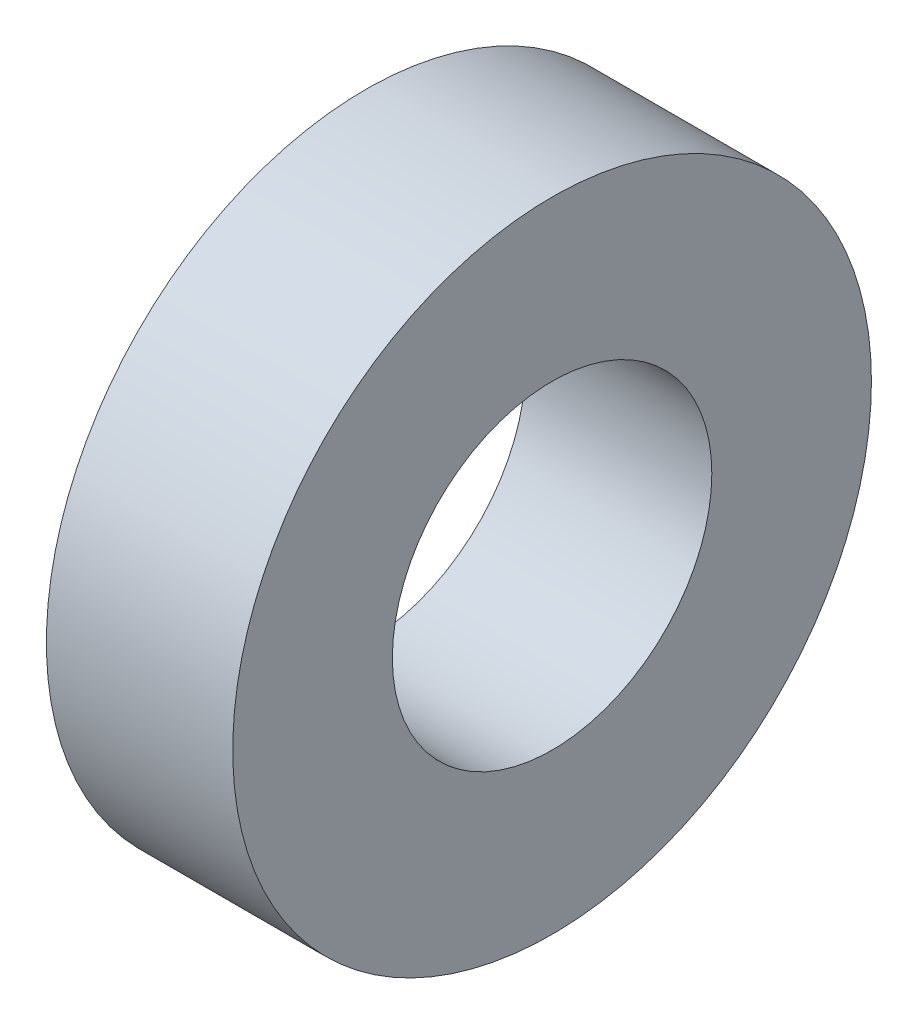
from build123d import *

# Parameters (mm, degrees)
SKETCH1_R           = 59.978111755
SKETCH1_R_2         = 30
BOSS_EXTRUDE2_DEPTH = 35


with BuildPart() as part:
    # Sketch1 → Boss-Extrude2 (new body)
    with BuildSketch(Plane(origin=(0, 0, 0), x_dir=(0, 0, -1), z_dir=(1, 0, 0))):
        Circle(SKETCH1_R)
        Circle(SKETCH1_R_2, mode=Mode.SUBTRACT)
    extrude(amount=BOSS_EXTRUDE2_DEPTH)


solid = part.part
